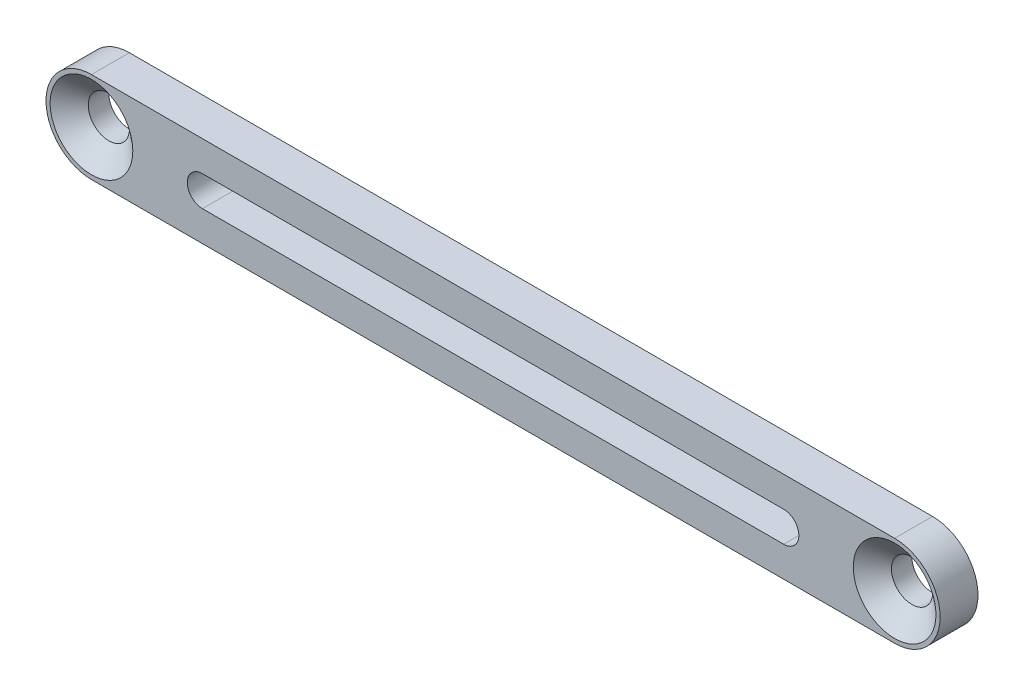
from build123d import *

# Parameters (mm, degrees)
BOSS_EXTRUDE1_DEPTH                               = 3.175
CSK_FOR_4_FLAT_HEAD_MACHINE_SCREW_100_D           = 3.4544
CSK_FOR_4_FLAT_HEAD_MACHINE_SCREW_100_CSINK_D     = 6.925818
CSK_FOR_4_FLAT_HEAD_MACHINE_SCREW_100_CSINK_ANGLE = 100
CUT_EXTRUDE1_DEPTH                                = 4.175


with BuildPart() as part:
    # Sketch1 → Boss-Extrude1 (new body)
    with BuildSketch(Plane.XY):
        with BuildLine():
            Line((5.469571116, 16.602717302), (72.76915781, 16.602717302))
            ThreePointArc((72.76915781, 16.602717302), (76.57915781, 20.412717302), (72.76915781, 24.222717302))
            Line((72.76915781, 24.222717302), (5.469571116, 24.222717302))
            ThreePointArc((5.469571116, 24.222717302), (1.659571116, 20.412717302), (5.469571116, 16.602717302))
        make_face()
    extrude(amount=BOSS_EXTRUDE1_DEPTH)

    # CSK for #4 Flat Head Machine Screw (100)1 (through all)
    with Locations(Plane.XY.offset(3.175)):
        with Locations((5.469571116, 20.412717302), (72.76915781, 20.412717302)):
            CounterSinkHole(CSK_FOR_4_FLAT_HEAD_MACHINE_SCREW_100_D / 2, CSK_FOR_4_FLAT_HEAD_MACHINE_SCREW_100_CSINK_D / 2, counter_sink_angle=CSK_FOR_4_FLAT_HEAD_MACHINE_SCREW_100_CSINK_ANGLE)

    # Sketch4 → Cut-Extrude1 (cut, through all)
    with BuildSketch(Plane(origin=(0, 0, 0), x_dir=(-1, 0, 0), z_dir=(0, 0, -1))):
        with BuildLine():
            Line((-63.47275781, 21.682717302), (-14.765971116, 21.682717302))
            ThreePointArc((-14.765971116, 21.682717302), (-13.495971116, 20.412717302), (-14.765971116, 19.142717302))
            Line((-14.765971116, 19.142717302), (-63.47275781, 19.142717302))
            ThreePointArc((-63.47275781, 19.142717302), (-64.74275781, 20.412717302), (-63.47275781, 21.682717302))
        make_face()
    extrude(amount=-CUT_EXTRUDE1_DEPTH, mode=Mode.SUBTRACT)


solid = part.part
